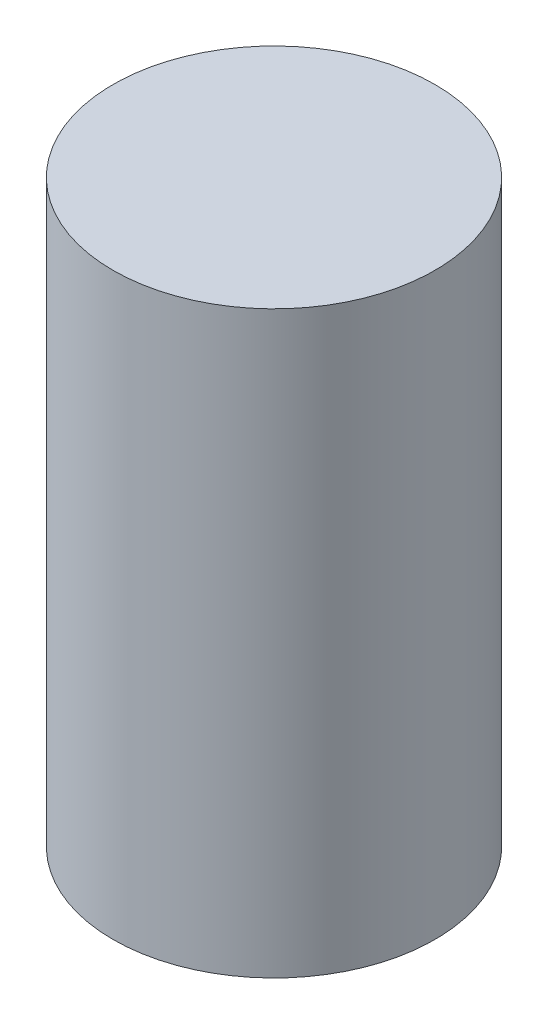
from build123d import *

# Parameters (mm, degrees)
SKETCH1_R           = 1.25
BOSS_EXTRUDE1_DEPTH = 4.5


with BuildPart() as part:
    # Sketch1 → Boss-Extrude1 (new body)
    with BuildSketch(Plane(origin=(0, 0, 0), x_dir=(1, 0, 0), z_dir=(0, 1, 0))):
        Circle(SKETCH1_R)
    extrude(amount=BOSS_EXTRUDE1_DEPTH)


solid = part.part
